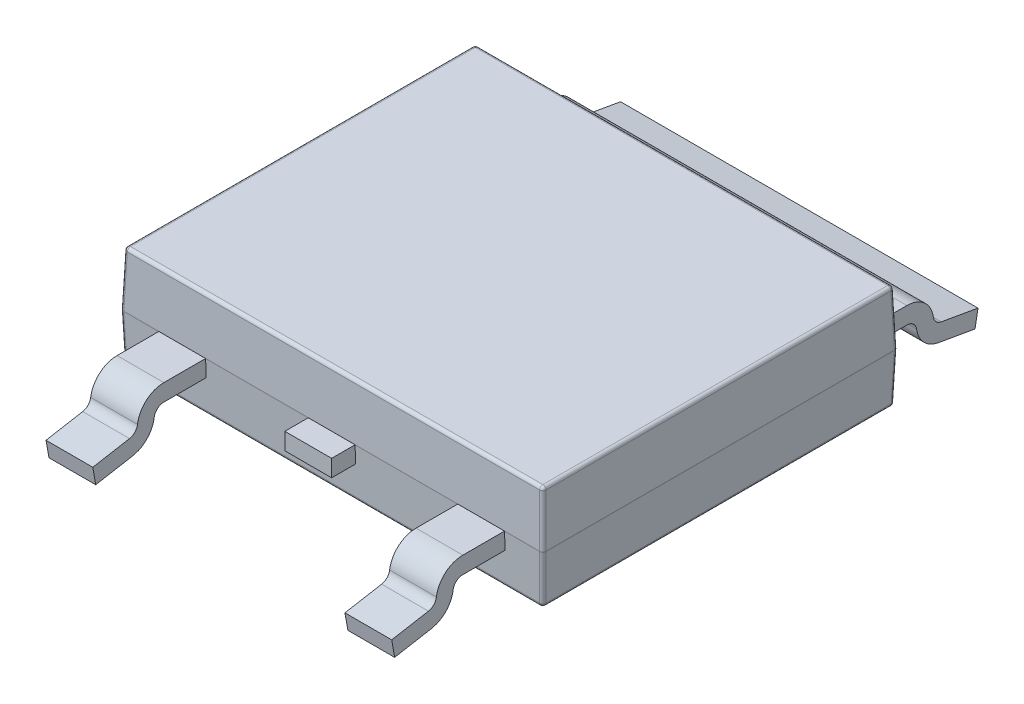
from build123d import *

# Parameters (mm, degrees)
SKETCH1_W                = 6.5
SKETCH1_H                = 5.46
EXTRUDE1_DEPTH           = 0.8375
EXTRUDE1_TAPER           = 2
EXTRUDE1_OTHER_WAY_DEPTH = 0.7625
EXTRUDE1_OTHER_WAY_TAPER = 2
FILLET1_R                = 0.05
EXTRUDE2_DEPTH           = 0.36
LPATTERN3_COUNT          = 2
LPATTERN3_PITCH          = 2.3
LPATTERN3_COL_COUNT      = 2
LPATTERN3_COL_PITCH      = 2.3
EXTRUDE3_DEPTH           = 2.75
ESBO_O1_W                = 1.566829661
ESBO_O1_H                = 1.760265422
CORTE_EXTRUS_O1_DEPTH    = 10


with BuildPart() as part:
    # Sketch1 → Extrude1 (new body)
    with BuildSketch(Plane(origin=(0, 0, 0), x_dir=(1, 0, 0), z_dir=(0, 1, 0))):
        Rectangle(SKETCH1_W, SKETCH1_H)
    extrude(amount=EXTRUDE1_DEPTH, taper=EXTRUDE1_TAPER)

    # Sketch1 → Extrude1 other way (add)
    with BuildSketch(Plane(origin=(0, 0, 0), x_dir=(1, 0, 0), z_dir=(0, 1, 0))):
        Rectangle(SKETCH1_W, SKETCH1_H)
    extrude(amount=-EXTRUDE1_OTHER_WAY_DEPTH, taper=EXTRUDE1_OTHER_WAY_TAPER)

    # Fillet1
    fillet1_edges = [part.edges().sort_by_distance(p)[0] for p in [
        (3.220753856, 0.8375, 0),
        (-3.223372913, -0.7625, 0),
        (-3.236686457, -0.38125, 2.716686457),
        (0, -0.7625, -2.703372913),
        (0, 0.8375, -2.700753856),
        (-3.236686457, -0.38125, -2.716686457),
        (3.223372913, -0.7625, 0),
        (3.236686457, -0.38125, -2.716686457),
        (0, -0.7625, 2.703372913),
        (3.236686457, -0.38125, 2.716686457),
        (-3.220753856, 0.8375, 0),
        (0, 0, -2.73),
        (3.25, 0, 0),
        (0, 0, 2.73),
        (-3.25, 0, 0),
        (0, 0.8375, 2.700753856),
        (-3.235376928, 0.41875, -2.715376928),
        (3.235376928, 0.41875, -2.715376928),
        (3.235376928, 0.41875, 2.715376928),
        (-3.235376928, 0.41875, 2.715376928),
    ]]
    fillet(fillet1_edges, radius=FILLET1_R)

    # Sketch2 → Extrude2 (add, symmetric)
    with BuildSketch(Plane(origin=(0, 0, 0), x_dir=(0, 0, -1), z_dir=(1, 0, 0))):
        with BuildLine():
            Line((0, 0), (0, -0.26))
            Line((0, -0.26), (-3.372304445, -0.26))
            ThreePointArc((-3.372304445, -0.26), (-3.470921786, -0.296975135), (-3.5209206, -0.389671731))
            ThreePointArc((-3.5209206, -0.389671731), (-3.631684309, -0.618373728), (-3.855942353, -0.737879092))
            Line((-3.855942353, -0.737879092), (-4.4209206, -0.8375))
            Line((-4.4209206, -0.8375), (-4.466069126, -0.581449984))
            Line((-4.466069126, -0.581449984), (-3.901090879, -0.481829076))
            ThreePointArc((-3.901090879, -0.481829076), (-3.819045257, -0.438107605), (-3.778521947, -0.35443615))
            ThreePointArc((-3.778521947, -0.35443615), (-3.641858541, -0.101065397), (-3.372304445, 0))
            Line((-3.372304445, 0), (0, 0))
        make_face()
    extrude2 = extrude(amount=EXTRUDE2_DEPTH, both=True)

    # LPattern3: Extrude2 ×2
    with Locations(*[(-i * LPATTERN3_PITCH, 0, 0) for i in range(1, LPATTERN3_COUNT)]):
        add(extrude2)

    # LPattern3 col: Extrude2 ×2
    with Locations(*[(i * LPATTERN3_COL_PITCH, 0, 0) for i in range(1, LPATTERN3_COL_COUNT)]):
        add(extrude2)

    # Sketch3 → Extrude3 (add, symmetric)
    with BuildSketch(Plane(origin=(0, 0, 0), x_dir=(0, 0, -1), z_dir=(1, 0, 0))):
        with BuildLine():
            Line((4.4209206, -0.8375), (3.855942353, -0.737879092))
            ThreePointArc((3.855942353, -0.737879092), (3.631684319, -0.618373739), (3.520920604, -0.389671762))
            ThreePointArc((3.520920604, -0.389671762), (3.470921797, -0.296975145), (3.372304445, -0.26))
            Line((3.372304445, -0.26), (0, -0.26))
            Line((0, -0.26), (0, 0))
            Line((0, 0), (3.372304445, 0))
            ThreePointArc((3.372304445, 0), (3.641858541, -0.101065397), (3.778521947, -0.35443615))
            ThreePointArc((3.778521947, -0.35443615), (3.819045257, -0.438107605), (3.901090879, -0.481829076))
            Line((3.901090879, -0.481829076), (4.466069126, -0.581449984))
            Line((4.466069126, -0.581449984), (4.4209206, -0.8375))
        make_face()
    extrude(amount=EXTRUDE3_DEPTH, both=True)

    # Esboço1 → Corte-extrusão1 (cut)
    with BuildSketch(Plane(origin=(0, 0, 0), x_dir=(1, 0, 0), z_dir=(0, 1, 0))):
        with Locations((-0.005950716, -3.970874351)):
            Rectangle(ESBO_O1_W, ESBO_O1_H)
    extrude(amount=-CORTE_EXTRUS_O1_DEPTH, mode=Mode.SUBTRACT)


solid = part.part
